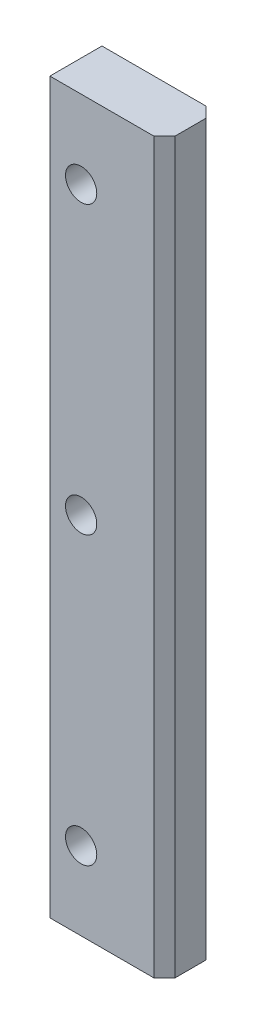
from build123d import *

# Parameters (mm, degrees)
SKETCH1_W           = 22
SKETCH1_H           = 140
BOSS_EXTRUDE1_DEPTH = 10
CHAMFER1_SIZE       = 2
SKETCH2_R           = 3
CUT_EXTRUDE1_DEPTH  = 11


with BuildPart() as part:
    # Sketch1 → Boss-Extrude1 (new body)
    with BuildSketch(Plane.XY):
        Rectangle(SKETCH1_W, SKETCH1_H)
    extrude(amount=BOSS_EXTRUDE1_DEPTH)

    # Chamfer1
    chamfer1_edges = [part.edges().sort_by_distance(p)[0] for p in [
        (11, 0, 0),
        (11, 0, 10),
    ]]
    chamfer(chamfer1_edges, length=CHAMFER1_SIZE)

    # Sketch2 → Cut-Extrude1 (cut, through all)
    with BuildSketch(Plane.XY.offset(10)):
        with Locations((-5, 55)):
            Circle(SKETCH2_R)
        with Locations((-5, 0)):
            Circle(SKETCH2_R)
        with Locations((-5, -55)):
            Circle(SKETCH2_R)
    extrude(amount=-CUT_EXTRUDE1_DEPTH, mode=Mode.SUBTRACT)


solid = part.part
